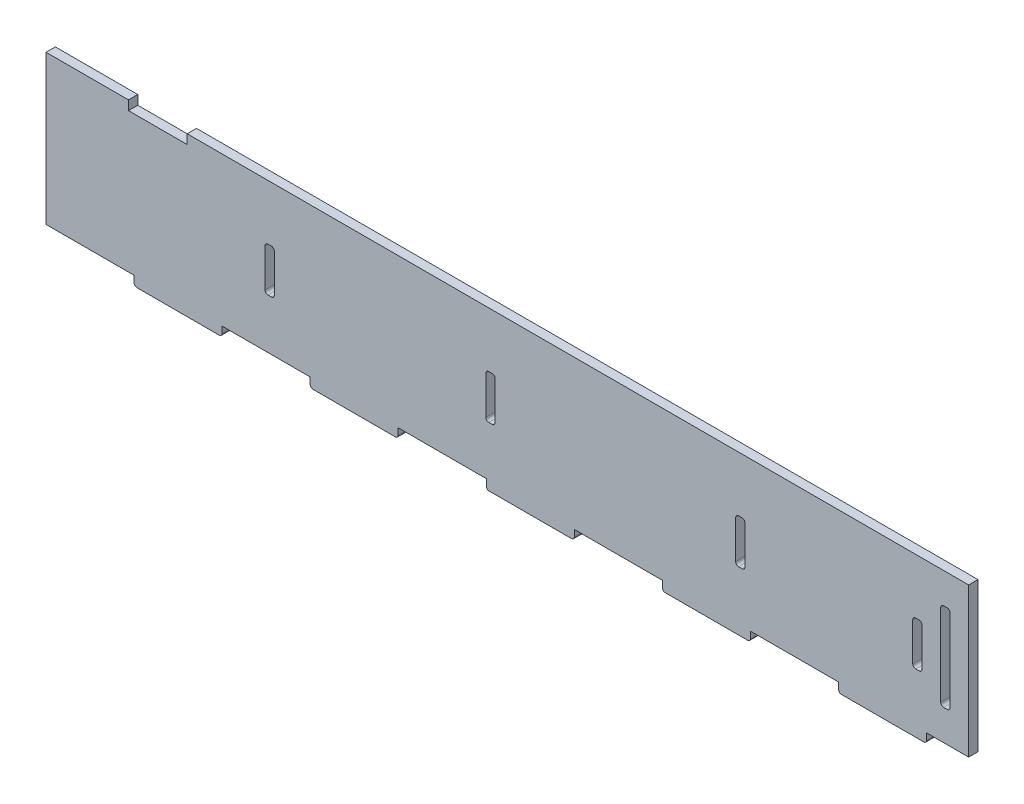
from build123d import *

# Parameters (mm, degrees)
SKETCH1_W           = 314.33
SKETCH1_H           = 50.8
BOSS_EXTRUDE1_DEPTH = 3.175
SKETCH2_W           = 3.175
SKETCH2_H           = 15
CUT_EXTRUDE1_DEPTH  = 4.175
SKETCH3_W           = 30
SKETCH3_H           = 3.175
BOSS_EXTRUDE2_DEPTH = 3.175
SKETCH4_W           = 3.175
SKETCH4_H           = 30
SKETCH4_H_2         = 15
CUT_EXTRUDE2_DEPTH  = 4.175
SKETCH5_W           = 20
SKETCH5_H           = 3.175
CUT_EXTRUDE3_DEPTH  = 4.175
FILLET1_R           = 1


with BuildPart() as part:
    # Sketch1 → Boss-Extrude1 (new body)
    with BuildSketch(Plane.XY):
        Rectangle(SKETCH1_W, SKETCH1_H)
    extrude(amount=BOSS_EXTRUDE1_DEPTH)

    # Sketch2 → Cut-Extrude1 (cut, through all)
    with BuildSketch(Plane.XY.offset(3.175)):
        with Locations((-80.9625, -0.9)):
            Rectangle(SKETCH2_W, SKETCH2_H)
        with Locations((-5.7375, -0.9)):
            Rectangle(SKETCH2_W, SKETCH2_H)
    extrude(amount=-CUT_EXTRUDE1_DEPTH, mode=Mode.SUBTRACT)

    # Sketch3 → Boss-Extrude2 (add)
    with BuildSketch(Plane.XZ.offset(25.4)):
        with Locations((-112.165, 1.5875)):
            Rectangle(SKETCH3_W, SKETCH3_H)
        with Locations((-52.165, 1.5875)):
            Rectangle(SKETCH3_W, SKETCH3_H)
        with Locations((127.835, 1.5875)):
            Rectangle(SKETCH3_W, SKETCH3_H)
        with Locations((67.835, 1.5875)):
            Rectangle(SKETCH3_W, SKETCH3_H)
        with Locations((7.835, 1.5875)):
            Rectangle(SKETCH3_W, SKETCH3_H)
    extrude(amount=BOSS_EXTRUDE2_DEPTH)

    # Sketch4 → Cut-Extrude2 (cut, through all)
    with BuildSketch(Plane.XY.offset(3.175)):
        with Locations((149.2275, 0)):
            Rectangle(SKETCH4_W, SKETCH4_H)
        with Locations((139.6975, -0.9)):
            Rectangle(SKETCH4_W, SKETCH4_H_2)
        with Locations((79.3725, -0.9)):
            Rectangle(SKETCH4_W, SKETCH4_H_2)
    extrude(amount=-CUT_EXTRUDE2_DEPTH, mode=Mode.SUBTRACT)

    # Sketch5 → Cut-Extrude3 (cut, through all)
    with BuildSketch(Plane.XY.offset(3.175)):
        with Locations((-119.065, 23.8125)):
            Rectangle(SKETCH5_W, SKETCH5_H)
    extrude(amount=-CUT_EXTRUDE3_DEPTH, mode=Mode.SUBTRACT)

    # Fillet1
    fillet1_edges = [part.edges().sort_by_distance(p)[0] for p in [
        (22.835, -28.575, 1.5875),
        (-7.165, -28.575, 1.5875),
        (147.64, -15, 1.5875),
        (147.64, 15, 1.5875),
        (150.815, 15, 1.5875),
        (150.815, -15, 1.5875),
        (141.285, 6.6, 1.5875),
        (141.285, -8.4, 1.5875),
        (138.11, -8.4, 1.5875),
        (138.11, 6.6, 1.5875),
        (80.96, 6.6, 1.5875),
        (80.96, -8.4, 1.5875),
        (77.785, -8.4, 1.5875),
        (77.785, 6.6, 1.5875),
        (-82.55, -8.4, 1.5875),
        (-82.55, 6.6, 1.5875),
        (-79.375, 6.6, 1.5875),
        (-79.375, -8.4, 1.5875),
        (-4.15, 6.6, 1.5875),
        (-4.15, -8.4, 1.5875),
        (-7.325, -8.4, 1.5875),
        (-7.325, 6.6, 1.5875),
        (-97.165, -28.575, 1.5875),
        (-127.165, -28.575, 1.5875),
        (-37.165, -28.575, 1.5875),
        (-67.165, -28.575, 1.5875),
        (142.835, -28.575, 1.5875),
        (112.835, -28.575, 1.5875),
        (82.835, -28.575, 1.5875),
        (52.835, -28.575, 1.5875),
    ]]
    fillet(fillet1_edges, radius=FILLET1_R)


solid = part.part
